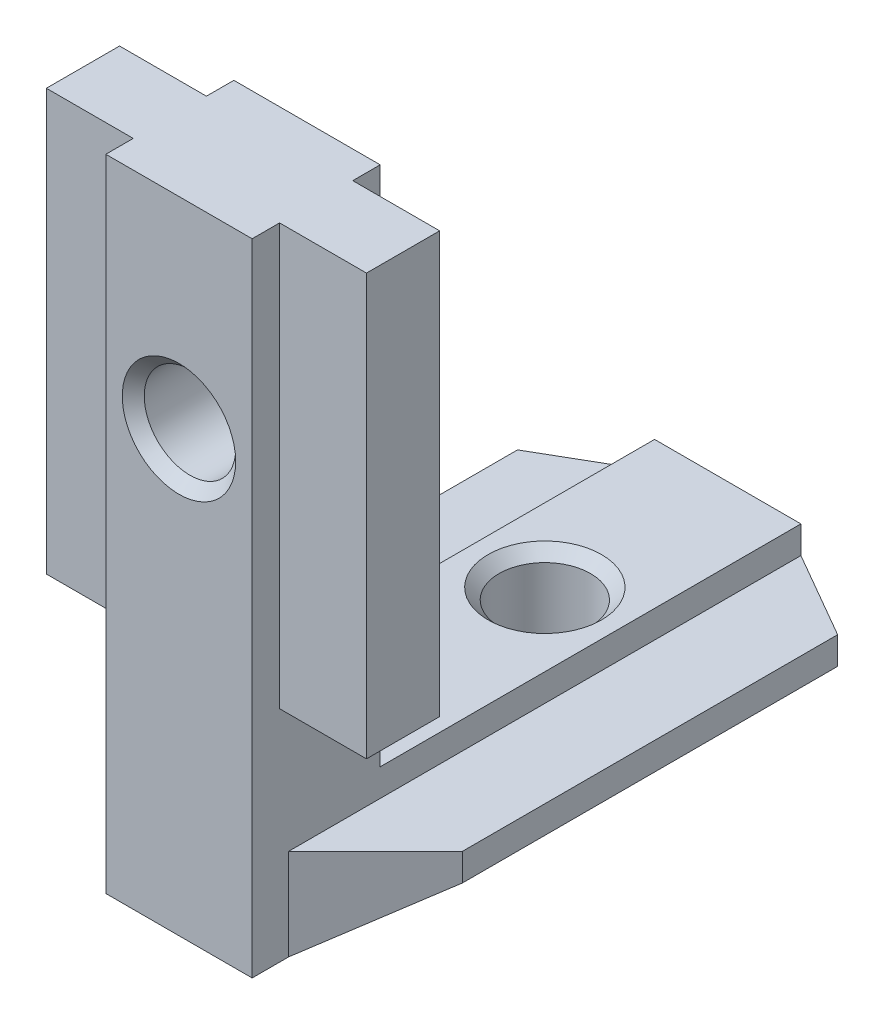
from build123d import *

# Parameters (mm, degrees)
EXTRUDE_1_DEPTH     = 30
SKETCH_2_W          = 7
SKETCH_2_H          = 35
EXTRUDE_2_DEPTH     = 4
CUT_EXTRUDE_1_DEPTH = 6
SKETCH_4_W          = 17.5
SKETCH_4_H          = 4
EXTRUDE_3_DEPTH     = 23


with BuildPart() as part:
    # Эскиз1 → Бобышка-Вытянуть1 (new body)
    with BuildSketch(Plane.XY):
        Polygon((4, 0), (-4, 0), (-4, -1.5), (-8.75, -1.5), (-8.75, -3), (-4, -6.5), (4, -6.5), (8.75, -3), (8.75, -1.5), (4, -1.5), align=None)
    extrude(amount=EXTRUDE_1_DEPTH)

    # Эскиз2 → Бобышка-Вытянуть2 (add, symmetric)
    with BuildSketch(Plane(origin=(0, 0, 0), x_dir=(0, 0, -1), z_dir=(1, 0, 0))):
        with Locations((-26.5, 11)):
            Rectangle(SKETCH_2_W, SKETCH_2_H)
    extrude(amount=EXTRUDE_2_DEPTH, both=True)

    # Эскиз3 → Вырез-Вытянуть1 (cut, through all)
    with BuildSketch(Plane(origin=(0, -1.5, 0), x_dir=(1, 0, 0), z_dir=(0, 1, 0))):
        Polygon((-4, 0), (-8.75, -2.742413779), (-8.75, 0), align=None)
        Polygon((-4, -28), (-8.75, -23.25), (-8.75, -30), (-4, -30), align=None)
        Polygon((4, -30), (4, -28), (8.75, -23.25), (8.75, -30), align=None)
        Polygon((8.75, 0), (4, 0), (8.75, -2.742413779), align=None)
    extrude(amount=-CUT_EXTRUDE_1_DEPTH, mode=Mode.SUBTRACT)

    # Эскиз4 → Бобышка-Вытянуть3 (add)
    with BuildSketch(Plane(origin=(0, 28.5, 0), x_dir=(1, 0, 0), z_dir=(0, 1, 0))):
        with Locations((0, -26.5)):
            Rectangle(SKETCH_4_W, SKETCH_4_H)
    extrude(amount=-EXTRUDE_3_DEPTH)

    # Эскиз6 → Отверстие обработанное метчиком M61 (revolve, cut)
    with BuildSketch(Plane(origin=(0, -6.5, 10), x_dir=(0, 0, -1), z_dir=(1, 0, 0))):
        Polygon((0, 0), (0, 6.5), (3.1, 6.5), (2.5, 5.9), (2.5, 0.6), (3.1, 0), align=None)
    revolve(axis=Axis((0, -12.85, 10), (0, 1, 0)), mode=Mode.SUBTRACT)

    # Эскиз8 → Отверстие обработанное метчиком M62 (revolve, cut)
    with BuildSketch(Plane(origin=(0, 17.5, 30), x_dir=(0, -1, 0), z_dir=(1, 0, 0))):
        Polygon((0, 0), (0, 7), (3.1, 7), (2.5, 6.4), (2.5, 0.6), (3.1, 0), align=None)
    revolve(axis=Axis((0, 17.5, 36.35), (0, 0, -1)), mode=Mode.SUBTRACT)


solid = part.part
